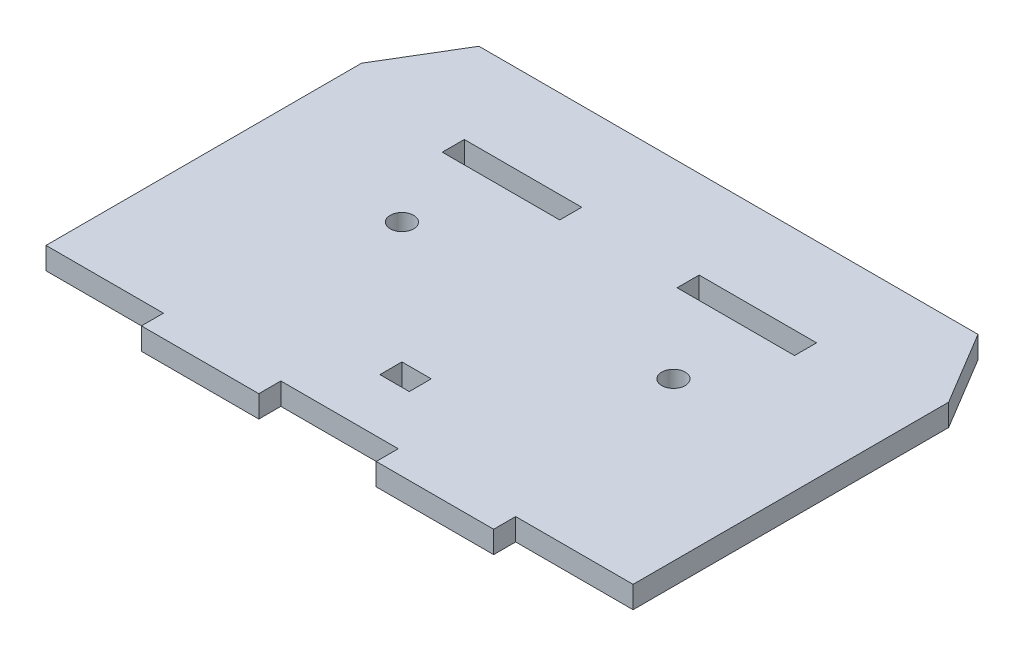
from build123d import *

# Parameters (mm, degrees)
BOSS_EXTRUDE1_DEPTH = 3
SKETCH2_R           = 1.6
SKETCH2_W           = 4
SKETCH2_H           = 3
SKETCH2_W_2         = 16
CUT_EXTRUDE1_DEPTH  = 4


with BuildPart() as part:
    # Sketch1 → Boss-Extrude1 (new body)
    with BuildSketch(Plane(origin=(0, 0, 0), x_dir=(1, 0, 0), z_dir=(0, 1, 0))):
        Polygon((-40, 37), (-34, 47), (34, 47), (40, 37), (40, -6), (24, -6), (24, -9), (8, -9), (8, -6), (-8, -6), (-8, -9), (-24, -9), (-24, -6), (-40, -6), align=None)
    extrude(amount=BOSS_EXTRUDE1_DEPTH)

    # Sketch2 → Cut-Extrude1 (cut, through all)
    with BuildSketch(Plane(origin=(0, 3, 0), x_dir=(1, 0, 0), z_dir=(0, 1, 0))):
        with Locations((-18.5, 21)):
            Circle(SKETCH2_R)
        with Locations((18.5, 21)):
            Circle(SKETCH2_R)
        with Locations((0, 3)):
            Rectangle(SKETCH2_W, SKETCH2_H)
        with Locations((-16, 33.5)):
            Rectangle(SKETCH2_W_2, SKETCH2_H)
        with Locations((16, 33.5)):
            Rectangle(SKETCH2_W_2, SKETCH2_H)
    extrude(amount=-CUT_EXTRUDE1_DEPTH, mode=Mode.SUBTRACT)


solid = part.part
